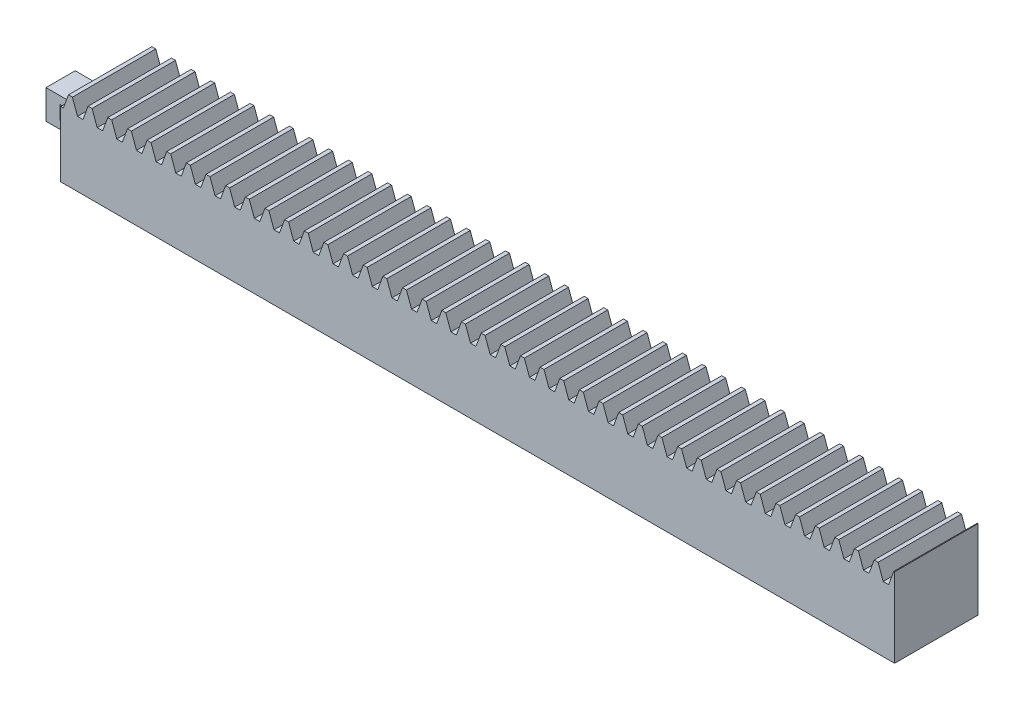
from build123d import *

# Parameters (mm, degrees)
BLANKSKE_W          = 200
BLANKSKE_H          = 19
BLANK_DEPTH         = 20
TOOTHCUTSIM_DEPTH   = 202.893536301
TEETHCUTS_COUNT     = 43
TEETHCUTS_PITCH     = 4.712388975
SKETCH3_W           = 7
SKETCH3_H           = 7
BOSS_EXTRUDE2_DEPTH = 10
SKETCH4_W           = 3.3
SKETCH4_H           = 3.3
CUT_EXTRUDE1_DEPTH  = 25


with BuildPart() as part:
    # BlankSke → Blank (new body)
    with BuildSketch(Plane.XY):
        with Locations((100, 9.5)):
            Rectangle(BLANKSKE_W, BLANKSKE_H)
    extrude(amount=-BLANK_DEPTH)

    # TooCutSkeSim → ToothCutSim (cut, through all)
    with BuildSketch(Plane.XY):
        Polygon((0.654653055, 15.625), (-0.654653055, 15.625), (-1.892297439, 19.0254), (1.892297439, 19.0254), align=None)
    toothcutsim = extrude(amount=-TOOTHCUTSIM_DEPTH, mode=Mode.SUBTRACT)

    # TeethCuts: ToothCutSim ×43
    with Locations(*[(i * TEETHCUTS_PITCH, 0, 0) for i in range(1, TEETHCUTS_COUNT)]):
        add(toothcutsim, mode=Mode.SUBTRACT)

    # Sketch3 → Boss-Extrude2 (add)
    with BuildSketch(Plane.ZY):
        with Locations((-10, 7.8125)):
            Rectangle(SKETCH3_W, SKETCH3_H)
    extrude(amount=BOSS_EXTRUDE2_DEPTH)

    # Sketch4 → Cut-Extrude1 (cut)
    with BuildSketch(Plane(origin=(0, 0, -13.5), x_dir=(-1, 0, 0), z_dir=(0, 0, -1))):
        with Locations((5, 7.8125)):
            Rectangle(SKETCH4_W, SKETCH4_H)
    extrude(amount=-CUT_EXTRUDE1_DEPTH, mode=Mode.SUBTRACT)


solid = part.part
